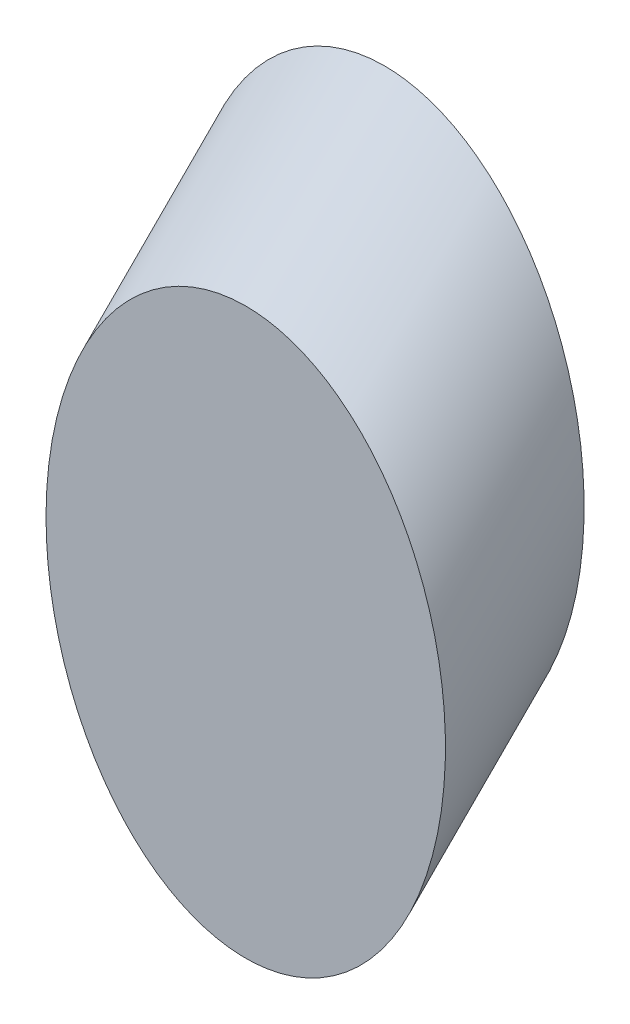
from build123d import *

# Parameters (mm, degrees)
SKETCH_1_RX     = 25.46
SKETCH_1_RY     = 18
EXTRUDE_2_DEPTH = 17.678


with BuildPart() as part:
    # 草图1 → 凸台-拉伸2 (new body, along a direction that is not the sketch's normal)
    with BuildSketch(Plane.XY):
        with Locations(Location((54.392382982, 35.78887153), (0, 0, -90))):
            Ellipse(SKETCH_1_RX, SKETCH_1_RY)
    extrude(amount=-EXTRUDE_2_DEPTH, dir=(0, -0.707106781, 0.707106781))


solid = part.part
